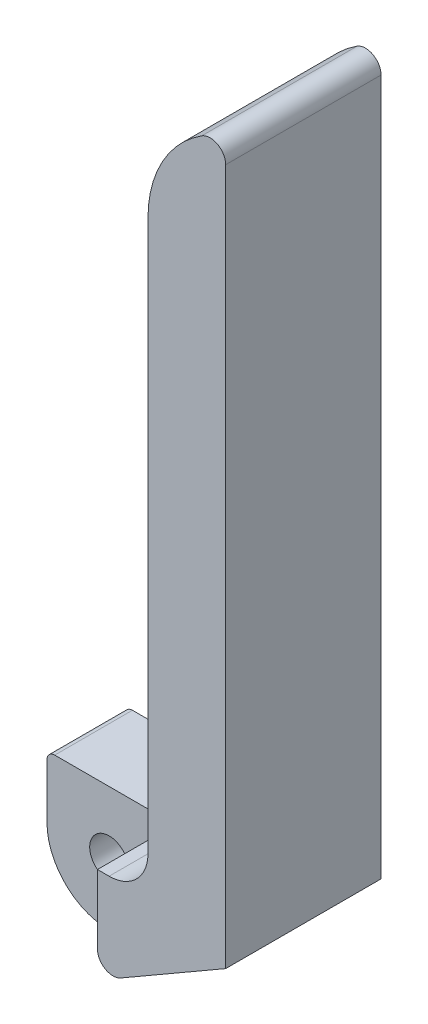
from build123d import *

# Parameters (mm, degrees)
SKETCH1_R           = 2.5
BOSS_EXTRUDE1_DEPTH = 20
CUT_EXTRUDE1_DEPTH  = 10


with BuildPart() as part:
    # Sketch1 → Boss-Extrude1 (new body)
    with BuildSketch(Plane.XY):
        with BuildLine():
            Line((-7, 8), (10, 8))
            ThreePointArc((10, 8), (13.535533906, 9.464466094), (15, 13))
            Line((15, 13), (15, 83.857864376))
            ThreePointArc((15, 83.857864376), (16.84412971, 91.063631297), (21.923076923, 96.497615703))
            ThreePointArc((21.923076923, 96.497615703), (23.960768923, 96.566431565), (25, 94.812315526))
            Line((25, 94.812315526), (25, 5.196152423))
            Line((25, 5.196152423), (4, -6.92820323))
            ThreePointArc((4, -6.92820323), (-4, -6.92820323), (-8, 0))
            Line((-8, 0), (-8, 7))
            ThreePointArc((-8, 7), (-7.707106781, 7.707106781), (-7, 8))
        make_face()
        Circle(SKETCH1_R, mode=Mode.SUBTRACT)
    extrude(amount=BOSS_EXTRUDE1_DEPTH)

    # Sketch2 → Cut-Extrude1 (cut)
    with BuildSketch(Plane.XY.offset(20)):
        with BuildLine():
            Line((8.5, 8), (8.5, -0.866025404))
            ThreePointArc((8.5, -0.866025404), (9.5, -2.598076211), (11.5, -2.598076211))
            Line((11.5, -2.598076211), (4, -6.92820323))
            ThreePointArc((4, -6.92820323), (-4, -6.92820323), (-8, 0))
            Line((-8, 0), (-8, 7))
            ThreePointArc((-8, 7), (-7.707106781, 7.707106781), (-7, 8))
            Line((-7, 8), (8.5, 8))
        make_face()
    extrude(amount=-CUT_EXTRUDE1_DEPTH, mode=Mode.SUBTRACT)


solid = part.part
